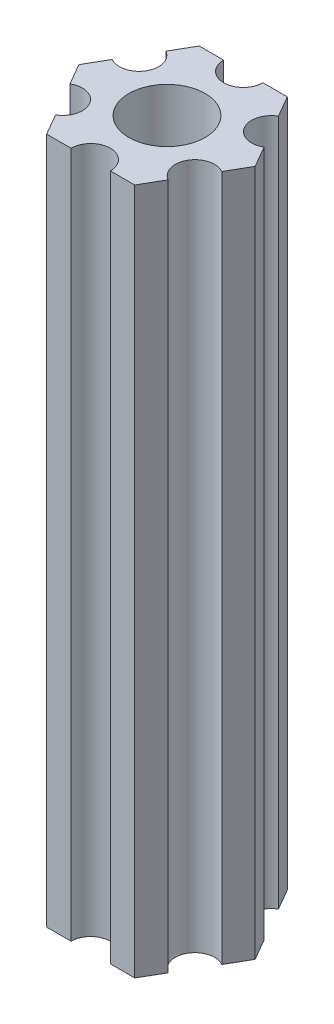
from build123d import *

# Parameters (mm, degrees)
SKETCH1_R           = 3.175
BOSS_EXTRUDE1_DEPTH = 57.15


with BuildPart() as part:
    # Sketch1 → Boss-Extrude1 (new body)
    with BuildSketch(Plane.XZ.offset(57.15)):
        with BuildLine():
            Line((-4.682174209, -4.59023638), (-3.666174209, -6.35))
            Line((-3.666174209, -6.35), (-1.634174209, -6.35))
            ThreePointArc((-1.634174209, -6.35), (0, -4.715825791), (1.634174209, -6.35))
            Line((1.634174209, -6.35), (3.666174209, -6.35))
            Line((3.666174209, -6.35), (4.682174209, -4.59023638))
            ThreePointArc((4.682174209, -4.59023638), (4.084024935, -2.357912895), (6.316348419, -1.75976362))
            Line((6.316348419, -1.75976362), (7.332348419, 0))
            Line((7.332348419, 0), (6.316348419, 1.75976362))
            ThreePointArc((6.316348419, 1.75976362), (4.084024935, 2.357912895), (4.682174209, 4.59023638))
            Line((4.682174209, 4.59023638), (3.666174209, 6.35))
            Line((3.666174209, 6.35), (1.634174209, 6.35))
            ThreePointArc((1.634174209, 6.35), (0, 4.715825791), (-1.634174209, 6.35))
            Line((-1.634174209, 6.35), (-3.666174209, 6.35))
            Line((-3.666174209, 6.35), (-4.682174209, 4.59023638))
            ThreePointArc((-4.682174209, 4.59023638), (-4.084024935, 2.357912895), (-6.316348419, 1.75976362))
            Line((-6.316348419, 1.75976362), (-7.332348419, 0))
            Line((-7.332348419, 0), (-6.316348419, -1.75976362))
            ThreePointArc((-6.316348419, -1.75976362), (-4.084024935, -2.357912895), (-4.682174209, -4.59023638))
        make_face()
        Circle(SKETCH1_R, mode=Mode.SUBTRACT)
    extrude(amount=-BOSS_EXTRUDE1_DEPTH)


solid = part.part
